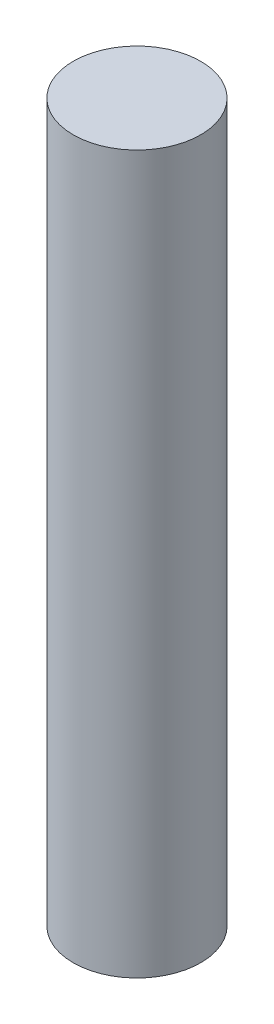
from build123d import *

# Parameters (mm, degrees)
SKETCH_1_W = 4
SKETCH_1_H = 45


with BuildPart() as part:
    # 草图1 → 旋转1 (revolve)
    with BuildSketch(Plane(origin=(0, 0, 0), x_dir=(-1, 0, 0), z_dir=(0, 0, -1))):
        with Locations((-62, -22.5)):
            Rectangle(SKETCH_1_W, SKETCH_1_H)
    revolve(axis=Axis((60, -45, 0), (0, 1, 0)))


solid = part.part
